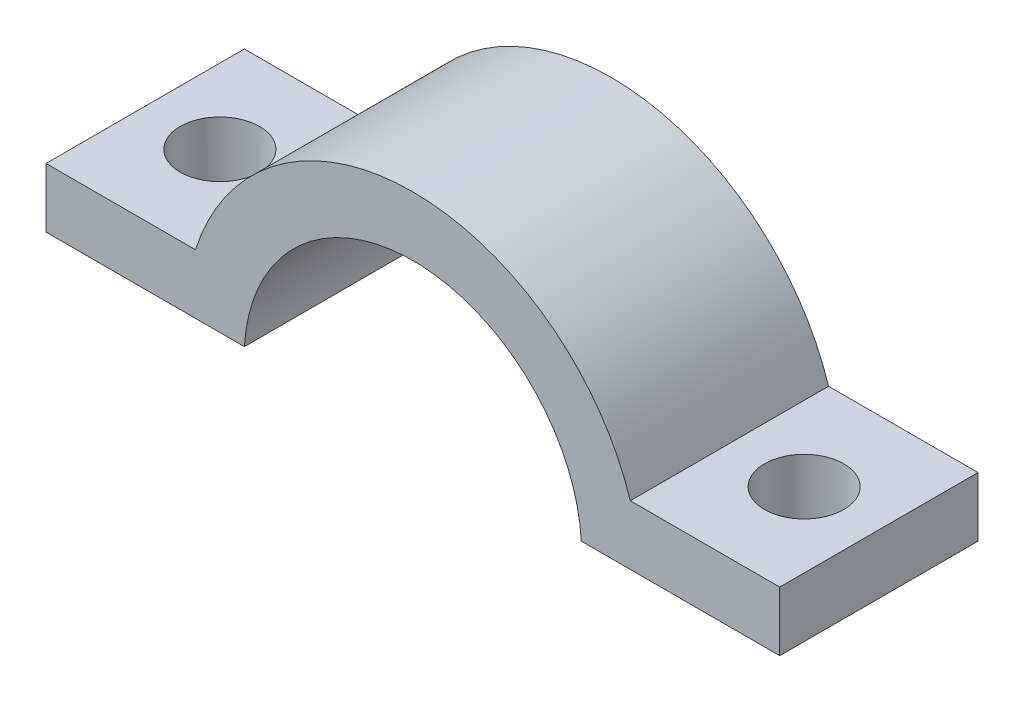
from build123d import *

# Parameters (mm, degrees)
BOSS_EXTRUDE1_DEPTH = 10
CUT_EXTRUDE3_REACH  = 13.51
SKETCH2_R           = 2


with BuildPart() as part:
    # Sketch1 → Boss-Extrude1 (new body)
    with BuildSketch(Plane.XY):
        with BuildLine():
            Line((8.4952987, 0.5), (18.5, 0.5))
            Line((18.5, 0.5), (18.5, 3.500157096))
            Line((18.5, 3.500157096), (10.964898554, 3.500157096))
            ThreePointArc((10.964898554, 3.500157096), (0, 11.51), (-10.964898554, 3.500157096))
            Line((-10.964898554, 3.500157096), (-18.5, 3.500157096))
            Line((-18.5, 3.500157096), (-18.5, 0.5))
            Line((-18.5, 0.5), (-8.4952987, 0.5))
            ThreePointArc((-8.4952987, 0.5), (0, 8.51), (8.4952987, 0.5))
        make_face()
    extrude(amount=BOSS_EXTRUDE1_DEPTH)

    # Sketch2 → Cut-Extrude3 (cut, up to next)
    with BuildSketch(Plane(origin=(0, 0, 0), x_dir=(1, 0, 0), z_dir=(0, 1, 0)), mode=Mode.PRIVATE) as cut_extrude3_sk1:
        with Locations((-14.732448989, -5)):
            Circle(SKETCH2_R)
    cut_extrude3_tool1 = extrude(cut_extrude3_sk1.sketch, amount=CUT_EXTRUDE3_REACH, mode=Mode.PRIVATE) & part.part
    add(cut_extrude3_tool1.solids().sort_by_distance((-14.732449, 0, 5))[0], mode=Mode.SUBTRACT)
    # Sketch2 → Cut-Extrude3 (cut, up to next)
    with BuildSketch(Plane(origin=(0, 0, 0), x_dir=(1, 0, 0), z_dir=(0, 1, 0)), mode=Mode.PRIVATE) as cut_extrude3_sk2:
        with Locations((14.732448989, -5)):
            Circle(SKETCH2_R)
    cut_extrude3_tool2 = extrude(cut_extrude3_sk2.sketch, amount=CUT_EXTRUDE3_REACH, mode=Mode.PRIVATE) & part.part
    add(cut_extrude3_tool2.solids().sort_by_distance((14.732449, 0, 5))[0], mode=Mode.SUBTRACT)


solid = part.part
